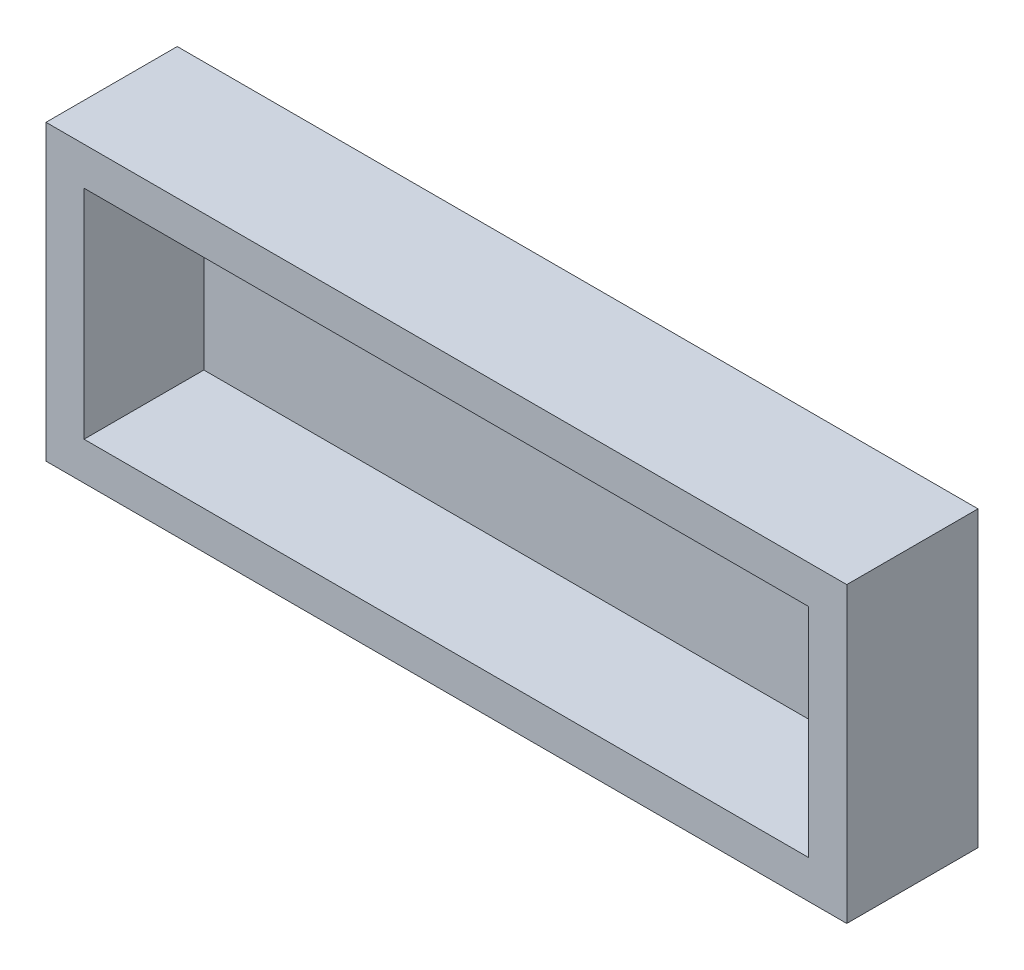
from build123d import *

# Parameters (mm, degrees)
SKETCH_2_W                 = 210.5009
SKETCH_2_H                 = 77.1505
EXTRUDE_1_DEPTH            = 34.5
SHELL_1_T                  = -10
SHELL_1_THICKNESS_2_FACE_W = 190.5009
SHELL_1_THICKNESS_2_FACE_H = 57.1505
SHELL_1_THICKNESS_2_DEPTH  = 7
SKETCH_3_R                 = 2
CUT_EXTRUDE_8_DEPTH        = 3


with BuildPart() as part:
    # 草图2 → 凸台-拉伸1 (new body)
    with BuildSketch(Plane.XY):
        with Locations((95.3455423, 28.832065)):
            Rectangle(SKETCH_2_W, SKETCH_2_H)
    extrude(amount=EXTRUDE_1_DEPTH)

    # 抽壳1
    shell_1_openings = [part.faces().sort_by_distance(p)[0] for p in [
        (95.3455423, 28.832065, 34.5),
    ]]
    offset(amount=SHELL_1_T, openings=shell_1_openings, kind=Kind.INTERSECTION)

    # 抽壳1 thickness 2 face (on inner face of the shell) → 抽壳1 thickness 2 (cut)
    with BuildSketch(Plane(origin=(95.3455423, 28.832065, 10), x_dir=(-1, 0, 0), z_dir=(0, 0, -1))):
        Rectangle(SHELL_1_THICKNESS_2_FACE_W, SHELL_1_THICKNESS_2_FACE_H)
    extrude(amount=SHELL_1_THICKNESS_2_DEPTH, mode=Mode.SUBTRACT)

    # 草图3 → 切除-拉伸8 (cut)
    with BuildSketch(Plane.XY):
        with Locations((38.19575, 38.357)):
            Circle(SKETCH_3_R)
    extrude(amount=CUT_EXTRUDE_8_DEPTH, mode=Mode.SUBTRACT)


solid = part.part
